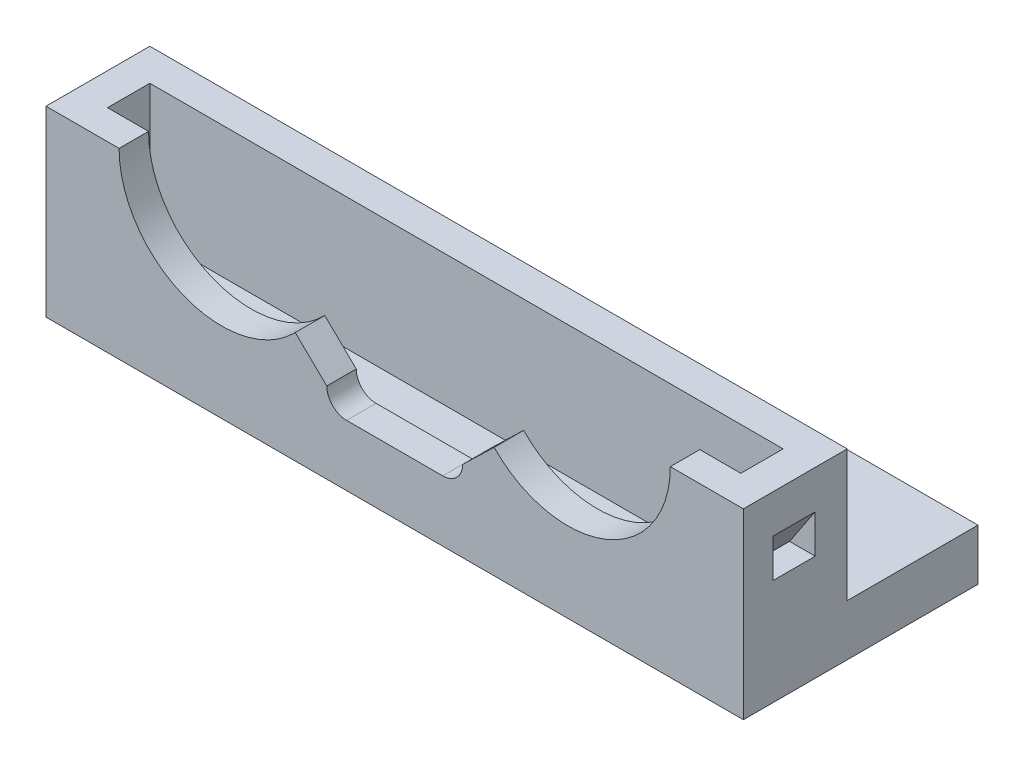
from build123d import *

# Parameters (mm, degrees)
SKETCH2_W           = 54.4
SKETCH2_H           = 16
BOSS_EXTRUDE1_DEPTH = 4
SKETCH3_W           = 2.3
SKETCH3_H           = 24
BOSS_EXTRUDE2_DEPTH = 54.4
SKETCH4_R           = 2.3
CUT_EXTRUDE1_DEPTH  = 45
CUT_EXTRUDE3_DEPTH  = 10
SKETCH5_R           = 8
CUT_EXTRUDE2_DEPTH  = 10
CUT_EXTRUDE4_DEPTH  = 10
SKETCH8_W           = 2.5
SKETCH8_H           = 10.25
BOSS_EXTRUDE3_DEPTH = 54.4
SKETCH9_W           = 2.5
SKETCH9_H           = 3.3
BOSS_EXTRUDE4_DEPTH = 10.25
CUT_EXTRUDE5_DEPTH  = 3.3


with BuildPart() as part:
    # Sketch2 → Boss-Extrude1 (new body)
    with BuildSketch(Plane(origin=(0, 0, 0), x_dir=(1, 0, 0), z_dir=(0, 1, 0))):
        Rectangle(SKETCH2_W, SKETCH2_H)
    extrude(amount=BOSS_EXTRUDE1_DEPTH)

    # Sketch3 → Boss-Extrude2 (add)
    with BuildSketch(Plane(origin=(27.2, 0, 0), x_dir=(0, 0, -1), z_dir=(1, 0, 0))):
        with Locations((-9.15, 12)):
            Rectangle(SKETCH3_W, SKETCH3_H)
    extrude(amount=-BOSS_EXTRUDE2_DEPTH)

    # Sketch4 → Cut-Extrude1 (cut)
    with BuildSketch(Plane(origin=(0, 4, 0), x_dir=(1, 0, 0), z_dir=(0, 1, 0))):
        with Locations((-13.5, 2.5)):
            Circle(SKETCH4_R)
        with Locations((13.5, 2.5)):
            Circle(SKETCH4_R)
    extrude(amount=-CUT_EXTRUDE1_DEPTH, mode=Mode.SUBTRACT)

    # Sketch6 → Cut-Extrude3 (cut)
    with BuildSketch(Plane.XY.offset(10.3)):
        with BuildLine():
            Line((-3.75, 7.85), (3.75, 7.85))
            ThreePointArc((3.75, 7.85), (5.3, 6.3), (3.75, 4.75))
            Line((3.75, 4.75), (-3.75, 4.75))
            ThreePointArc((-3.75, 4.75), (-5.3, 6.3), (-3.75, 7.85))
        make_face()
    extrude(amount=-CUT_EXTRUDE3_DEPTH, mode=Mode.SUBTRACT)

    # Sketch5 → Cut-Extrude2 (cut)
    with BuildSketch(Plane.XY.offset(10.3)):
        with Locations((-13.5, 14.25)):
            Circle(SKETCH5_R)
        with Locations((13.5, 14.25)):
            Circle(SKETCH5_R)
    extrude(amount=-CUT_EXTRUDE2_DEPTH, mode=Mode.SUBTRACT)

    # Sketch7 → Cut-Extrude4 (cut)
    with BuildSketch(Plane.XY.offset(10.3)):
        Polygon((-35.24269893, 14.25), (-13.5, 14.25), (-5.3, 6.3), (0, 6.5), (5.3, 6.3), (13.5, 14.25), (21.5, 14.25), (36.006358293, 14.25), (36.006358293, 27.887641337), (-35.24269893, 27.887641337), align=None)
    extrude(amount=-CUT_EXTRUDE4_DEPTH, mode=Mode.SUBTRACT)

    # Sketch8 → Boss-Extrude3 (add)
    with BuildSketch(Plane(origin=(27.2, 0, 0), x_dir=(0, 0, -1), z_dir=(1, 0, 0))):
        with Locations((-3.45, 9.125)):
            Rectangle(SKETCH8_W, SKETCH8_H)
    extrude(amount=-BOSS_EXTRUDE3_DEPTH)

    # Sketch9 → Boss-Extrude4 (add)
    with BuildSketch(Plane(origin=(0, 4, 0), x_dir=(1, 0, 0), z_dir=(0, 1, 0))):
        with Locations((-25.95, -6.35)):
            Rectangle(SKETCH9_W, SKETCH9_H)
        with Locations((25.95, -6.35)):
            Rectangle(SKETCH9_W, SKETCH9_H)
    extrude(amount=BOSS_EXTRUDE4_DEPTH)

    # Sketch10 → Cut-Extrude5 (cut)
    with BuildSketch(Plane.XY.offset(4.7)):
        Polygon((-27.2, 8.25), (-25.2, 8.25), (-27.2, 11.25), align=None)
        Polygon((27.2, 11.25), (27.2, 8.25), (25.2, 8.25), align=None)
    extrude(amount=CUT_EXTRUDE5_DEPTH, mode=Mode.SUBTRACT)


solid = part.part
